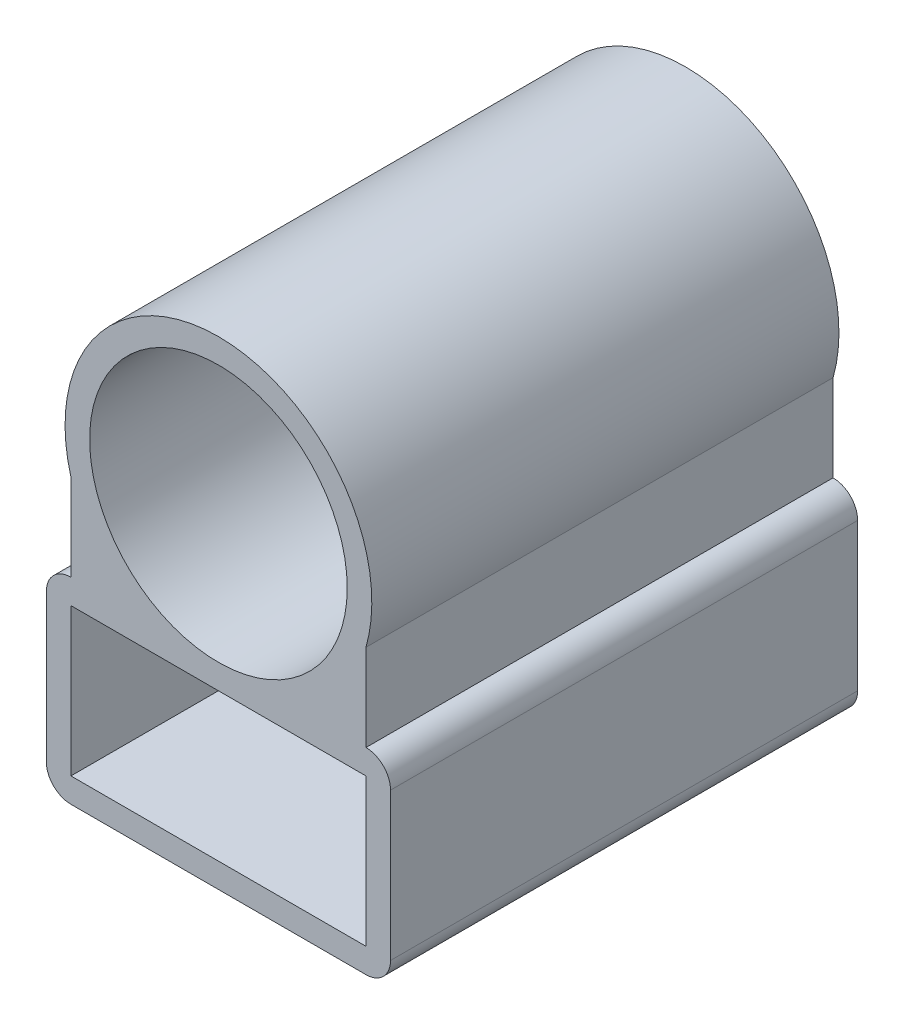
from build123d import *

# Parameters (mm, degrees)
SKETCH1_R           = 52.3875
SKETCH1_W           = 120
SKETCH1_H           = 60
BOSS_EXTRUDE1_DEPTH = 190


with BuildPart() as part:
    # Sketch1 → Boss-Extrude1 (new body)
    with BuildSketch(Plane.XY):
        with BuildLine():
            Line((-70, -62.3875), (-70, -122.3875))
            ThreePointArc((-70, -122.3875), (-67.071067812, -129.458567812), (-60, -132.3875))
            Line((-60, -132.3875), (60, -132.3875))
            ThreePointArc((60, -132.3875), (67.071067812, -129.458567812), (70, -122.3875))
            Line((70, -122.3875), (70, -62.3875))
            ThreePointArc((70, -62.3875), (67.071067812, -55.316432188), (60, -52.3875))
            Line((60, -52.3875), (60, -17.093863117))
            ThreePointArc((60, -17.093863117), (0, 62.3875), (-60, -17.093863117))
            Line((-60, -17.093863117), (-60, -52.3875))
            ThreePointArc((-60, -52.3875), (-67.071067812, -55.316432188), (-70, -62.3875))
        make_face()
        Circle(SKETCH1_R, mode=Mode.SUBTRACT)
        with Locations((0, -92.3875)):
            Rectangle(SKETCH1_W, SKETCH1_H, mode=Mode.SUBTRACT)
    extrude(amount=BOSS_EXTRUDE1_DEPTH)


solid = part.part
